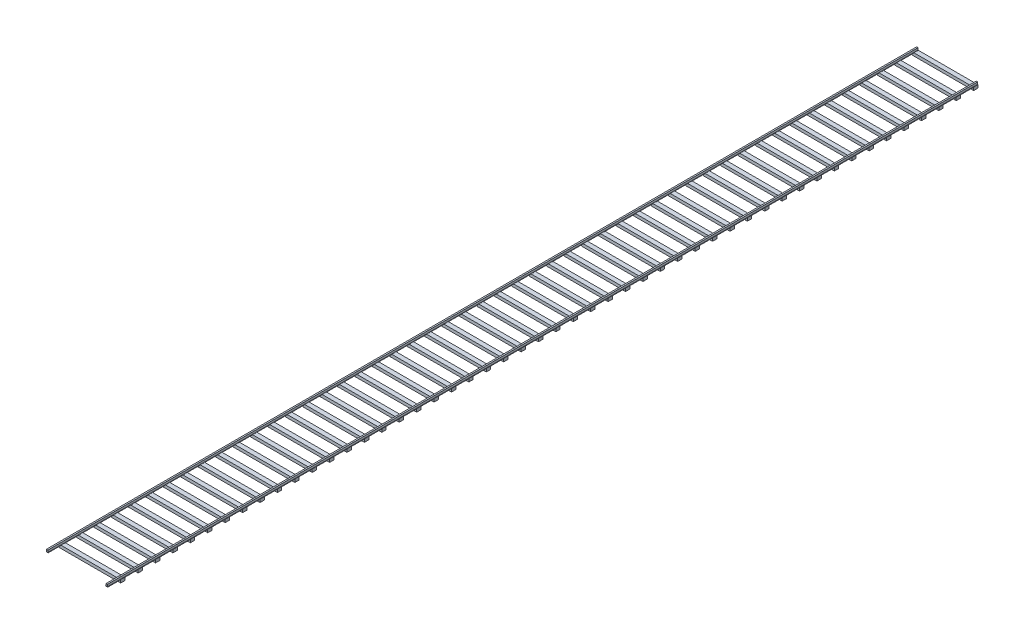
from build123d import *

# Parameters (mm, degrees)
BOSS_EXTRUDE1_DEPTH   = 30480
BOSS_EXTRUDE1_2_DEPTH = 30480
SKETCH2_W             = 2159
SKETCH2_H             = 152.4
BOSS_EXTRUDE3_DEPTH   = 101.6
LPATTERN1_COUNT       = 50
LPATTERN1_PITCH       = 609.6


with BuildPart() as part:
    # Sketch1 → Boss-Extrude1 (new body)
    with BuildSketch(Plane.XY):
        Polygon((1988.494239203, 32.566314021), (1988.494239203, 36.842382364), (2001.194239203, 36.842382364), (2001.194239203, 110.913708573), (2051.994239203, 110.913708573), (2051.994239203, 36.842382364), (2064.694239203, 36.842382364), (2064.694239203, 32.566314021), align=None)
    extrude(amount=BOSS_EXTRUDE1_DEPTH)

    # Sketch2 → Boss-Extrude3 (add)
    with BuildSketch(Plane.XZ.offset(-32.566314021)):
        with Locations((985.194239203, 76.2)):
            Rectangle(SKETCH2_W, SKETCH2_H)
    boss_extrude3 = extrude(amount=BOSS_EXTRUDE3_DEPTH)

    # LPattern1: Boss-Extrude3 ×50
    with Locations(*[(0, 0, i * LPATTERN1_PITCH) for i in range(1, LPATTERN1_COUNT)]):
        add(boss_extrude3)


with BuildPart() as body_2:
    # Sketch1 → Boss-Extrude1 2 (new body)
    with BuildSketch(Plane.XY):
        Polygon((-81.605760797, 110.913708573), (-30.805760797, 110.913708573), (-30.805760797, 36.842382364), (-18.105760797, 36.842382364), (-18.105760797, 34.713708573), (-94.305760797, 34.713708573), (-94.305760797, 36.842382364), (-81.605760797, 36.842382364), align=None)
    extrude(amount=BOSS_EXTRUDE1_2_DEPTH)


solid = Compound([part.part, body_2.part])
